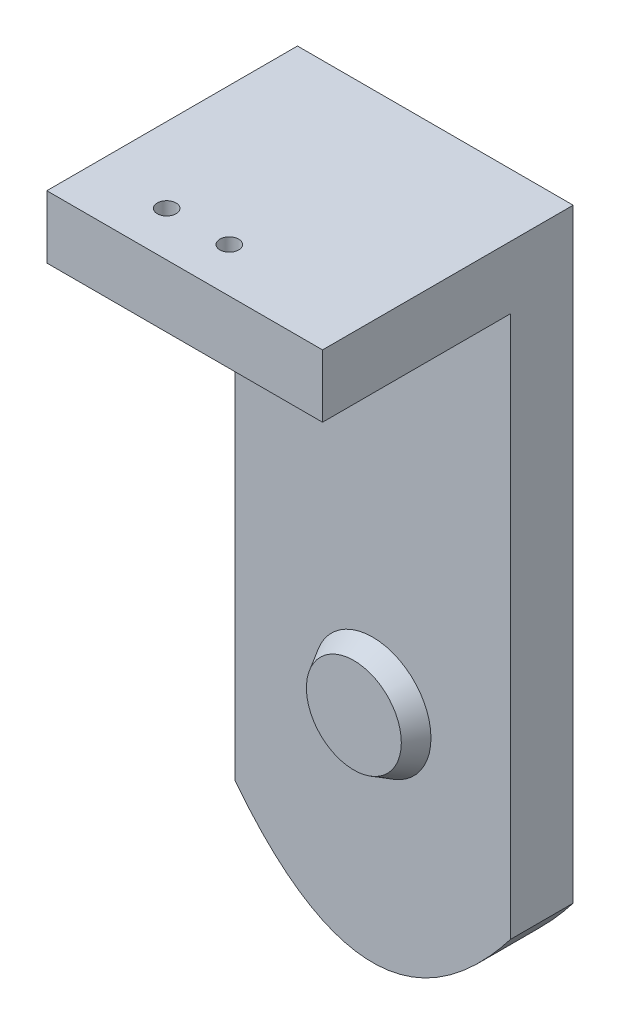
from build123d import *

# Parameters (mm, degrees)
EXTRUDE_1_DEPTH        = 10
SKETCH_1_R             = 6
CUT_EXTRUDE_1_DEPTH    = 23
SKETCH_3_W             = 44
SKETCH_3_H             = 10
EXTRUDE_2_DEPTH        = 30
SKETCH_4_R             = 1.5
CUT_EXTRUDE_2_DEPTH    = 15
PATTERN_LINEAR_1_COUNT = 2
PATTERN_LINEAR_1_PITCH = 10
SKETCH_5_R             = 7.573705131
EXTRUDE_3_DEPTH        = 3
DRAFT_1_ANGLE          = 30


with BuildPart() as part:
    # 草图2 → 凸台-拉伸1 (new body)
    with BuildSketch(Plane.XY):
        with BuildLine():
            Line((-22, 75), (22, 75))
            Line((22, 75), (22, -21.471774194))
            add(Edge.make_bspline(
                [(-22, -21.471774194), (0, -49.899193548), (22, -21.471774194)],
                knots=[0, 0, 0, 1, 1, 1], degree=2))
            Line((-22, -21.471774194), (-22, 75))
        make_face()
    extrude(amount=EXTRUDE_1_DEPTH)

    # 草图1 → 切除-拉伸1 (cut)
    with BuildSketch(Plane.XY):
        Circle(SKETCH_1_R)
    extrude(amount=CUT_EXTRUDE_1_DEPTH, mode=Mode.SUBTRACT)

    # 草图3 → 凸台-拉伸2 (add)
    with BuildSketch(Plane.XY.offset(10)):
        with Locations((0, 70)):
            Rectangle(SKETCH_3_W, SKETCH_3_H)
    extrude(amount=EXTRUDE_2_DEPTH)

    # 草图4 → 切除-拉伸2 (cut)
    with BuildSketch(Plane(origin=(0, 75, 0), x_dir=(1, 0, 0), z_dir=(0, 1, 0))):
        with Locations((0, -32.875114596)):
            Circle(SKETCH_4_R)
    cut_extrude_2 = extrude(amount=-CUT_EXTRUDE_2_DEPTH, mode=Mode.SUBTRACT)

    # 阵列(线性)1: 切除-拉伸2 ×2
    with Locations(*[(-i * PATTERN_LINEAR_1_PITCH, 0, 0) for i in range(1, PATTERN_LINEAR_1_COUNT)]):
        add(cut_extrude_2, mode=Mode.SUBTRACT)

    # 草图5 → 凸台-拉伸3 (add)
    with BuildSketch(Plane.XY.offset(10)):
        Circle(SKETCH_5_R)
    extrude(amount=EXTRUDE_3_DEPTH)

    # 拔模1
    draft_1_faces = [part.faces().sort_by_distance(p)[0] for p in [
        (-7.573705131, 0, 11.5),
    ]]
    draft(draft_1_faces, Plane.XY.offset(13), DRAFT_1_ANGLE)


solid = part.part
